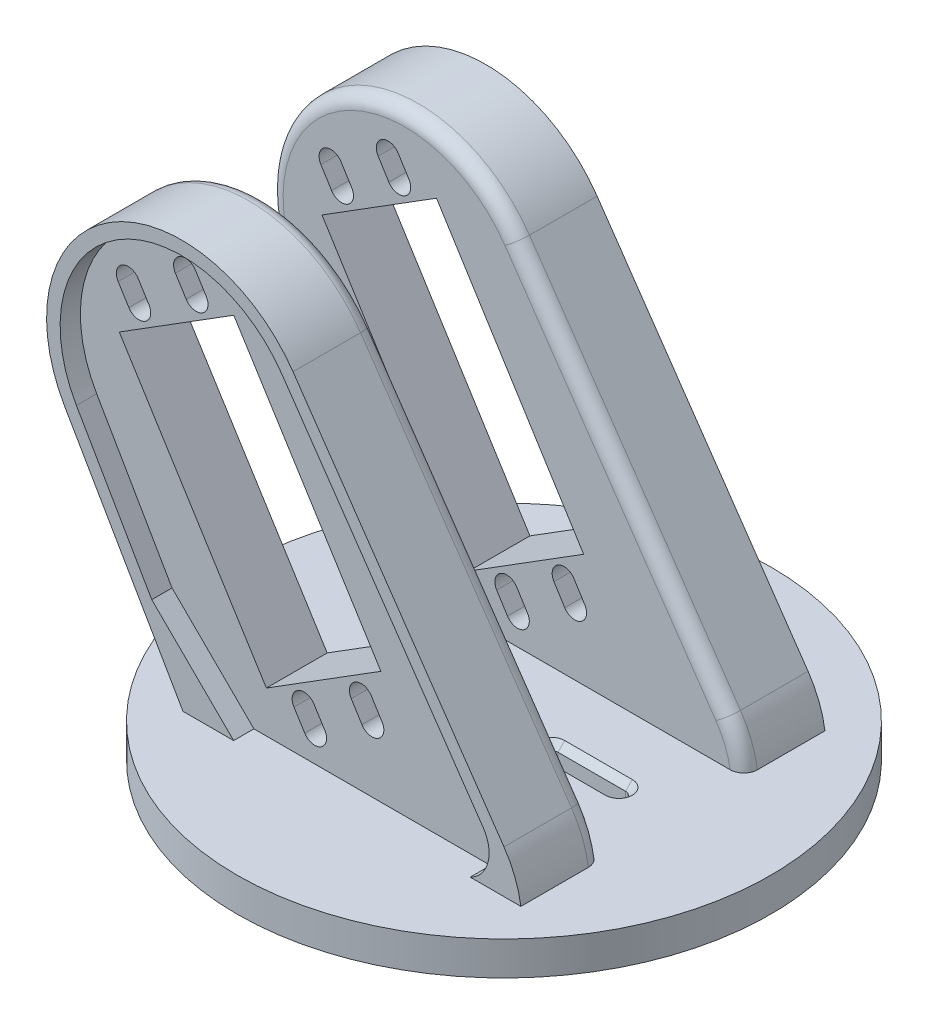
from build123d import *

# Parameters (mm, degrees)
SKETCH2_R               = 39.5
BOSS_EXTRUDE1_DEPTH     = 5
SKETCH3_R               = 1.625
CUT_EXTRUDE1_DEPTH      = 1
CUT_EXTRUDE1_DEPTH_BACK = 5
CUT_EXTRUDE2_DEPTH      = 2
BOSS_EXTRUDE2_DEPTH     = 12
CUT_EXTRUDE4_DEPTH      = 3
CUT_EXTRUDE5_DEPTH      = 9
SKETCH9_R               = 3
CUT_EXTRUDE6_DEPTH      = 2
FILLET3_R               = 2
CHAMFER6_SIZE           = 1


with BuildPart() as part:
    # Sketch2 → Boss-Extrude1 (new body)
    with BuildSketch(Plane(origin=(0, 0, 0), x_dir=(1, 0, 0), z_dir=(0, 1, 0))):
        Circle(SKETCH2_R)
    extrude(amount=BOSS_EXTRUDE1_DEPTH)

    # Sketch3 → Cut-Extrude1 (cut, two sides)
    with BuildSketch(Plane(origin=(0, 5, 0), x_dir=(1, 0, 0), z_dir=(0, 1, 0))) as cut_extrude1_sk:
        Circle(SKETCH3_R)
        with BuildLine():
            Line((7, 1), (17, 1))
            ThreePointArc((17, 1), (18, 0), (17, -1))
            Line((17, -1), (7, -1))
            ThreePointArc((7, -1), (6, 0), (7, 1))
        make_face()
        with BuildLine():
            Line((-7, 1), (-17, 1))
            ThreePointArc((-17, 1), (-18, 0), (-17, -1))
            Line((-17, -1), (-7, -1))
            ThreePointArc((-7, -1), (-6, 0), (-7, 1))
        make_face()
    extrude(amount=CUT_EXTRUDE1_DEPTH, mode=Mode.SUBTRACT)
    extrude(cut_extrude1_sk.sketch, amount=-CUT_EXTRUDE1_DEPTH_BACK, mode=Mode.SUBTRACT)

    # Sketch4 → Cut-Extrude2 (cut)
    with BuildSketch(Plane.XZ):
        with BuildLine():
            Line((-20, -5), (-20, 5))
            Line((-20, 5), (-5, 5))
            ThreePointArc((-5, 5), (0, 7.68337521), (5, 5))
            Line((5, 5), (20, 5))
            Line((20, 5), (20, -5))
            Line((20, -5), (5, -5))
            ThreePointArc((5, -5), (0, -7.68337521), (-5, -5))
            Line((-5, -5), (-20, -5))
        make_face()
    extrude(amount=-CUT_EXTRUDE2_DEPTH, mode=Mode.SUBTRACT)

    # Sketch9 → Cut-Extrude6 (cut)
    with BuildSketch(Plane(origin=(0, 5, 0), x_dir=(1, 0, 0), z_dir=(0, 1, 0))):
        Circle(SKETCH9_R)
    extrude(amount=-CUT_EXTRUDE6_DEPTH, mode=Mode.SUBTRACT)

    # Chamfer6
    chamfer6_edges = [part.edges().sort_by_distance(p)[0] for p in [
        (-6, 5, 0),
        (-12, 5, -1),
        (-18, 5, 0),
        (-12, 5, 1),
        (6, 5, 0),
        (12, 5, 1),
        (18, 5, 0),
        (12, 5, -1),
    ]]
    chamfer(chamfer6_edges, length=CHAMFER6_SIZE)


with BuildPart() as body_2:
    # Sketch5 → Boss-Extrude2 (new body)
    with BuildSketch(Plane.XY.offset(10.5)):
        with BuildLine():
            Line((-25, 5.000214176), (25, 5.000214176))
            ThreePointArc((25, 5.000214176), (24.120341075, 8.333931188), (22.502726521, 11.378728735))
            Line((22.502726521, 11.378728735), (-8.712776769, 56.662195413))
            ThreePointArc((-8.712776769, 56.662195413), (-35.86356999, 62.218216482), (-42.5, 35.311103308))
            Line((-42.5, 35.311103308), (-25, 5.000214176))
        make_face()
    extrude(amount=BOSS_EXTRUDE2_DEPTH)

    # Sketch6 → Cut-Extrude4 (cut)
    with BuildSketch(Plane.XY.offset(22.5)):
        with BuildLine():
            Line((-17.5, 5.000214176), (17.5, 5.000214176))
            ThreePointArc((17.5, 5.000214176), (20.13890591, 8.224855257), (19.418589077, 12.328911563))
            Line((19.418589077, 12.328911563), (-10.359448284, 55.527086203))
            ThreePointArc((-10.359448284, 55.527086203), (-34.795162183, 60.527505165), (-40.767949192, 36.311103308))
            Line((-40.767949192, 36.311103308), (-29.618802154, 17.000214176))
            Line((-29.618802154, 17.000214176), (-17.5, 5.000214176))
        make_face()
    extrude(amount=-CUT_EXTRUDE4_DEPTH, mode=Mode.SUBTRACT)

    # Sketch8 → Cut-Extrude5 (cut)
    with BuildSketch(Plane.XY.offset(19.5)):
        Polygon((-37.428003544, 45.896437317), (-15.657296014, 11.154009456), (1.290229772, 21.773866788), (-20.480477758, 56.516294649), align=None)
        with BuildLine():
            Line((-29.120728477, 57.59266239), (-27.527749877, 55.050533522))
            ThreePointArc((-27.527749877, 55.050533522), (-25.115603854, 54.496862533), (-24.561932865, 56.909008555))
            Line((-24.561932865, 56.909008555), (-26.154911464, 59.451137423))
            ThreePointArc((-26.154911464, 59.451137423), (-28.567057487, 60.004808413), (-29.120728477, 57.59266239))
        make_face()
        with BuildLine():
            Line((-3.102078014, 16.071224215), (-1.509099415, 13.529095347))
            ThreePointArc((-1.509099415, 13.529095347), (0.903046608, 12.975424358), (1.456717598, 15.38757038))
            Line((1.456717598, 15.38757038), (-0.136261002, 17.929699248))
            ThreePointArc((-0.136261002, 17.929699248), (-2.548407025, 18.483370238), (-3.102078014, 16.071224215))
        make_face()
        with BuildLine():
            Line((-11.575840907, 10.76129555), (-9.982862308, 8.219166682))
            ThreePointArc((-9.982862308, 8.219166682), (-7.570716285, 7.665495692), (-7.017045295, 10.077641715))
            Line((-7.017045295, 10.077641715), (-8.610023895, 12.619770583))
            ThreePointArc((-8.610023895, 12.619770583), (-11.022169918, 13.173441572), (-11.575840907, 10.76129555))
        make_face()
        with BuildLine():
            Line((-34.628674357, 54.141208757), (-33.035695757, 51.59907989))
            ThreePointArc((-33.035695757, 51.59907989), (-33.589366747, 49.186933867), (-36.00151277, 49.740604857))
            Line((-36.00151277, 49.740604857), (-37.59449137, 52.282733724))
            ThreePointArc((-37.59449137, 52.282733724), (-37.04082038, 54.694879747), (-34.628674357, 54.141208757))
        make_face()
    extrude(amount=-CUT_EXTRUDE5_DEPTH, mode=Mode.SUBTRACT)

    # Fillet3
    fillet3_edges = [body_2.edges().sort_by_distance(p)[0] for p in [
        (-35.86356999, 62.218216482, 10.5),
        (6.894974876, 34.020462074, 10.5),
        (24.120341075, 8.333931188, 10.5),
        (-33.75, 20.155658742, 10.5),
    ]]
    fillet(fillet3_edges, radius=FILLET3_R)


with BuildPart() as body_3:
    # Mirror1: mirrored copy
    add(body_2.part.mirror(Plane.XY))


solid = Compound([part.part, body_2.part, body_3.part])
